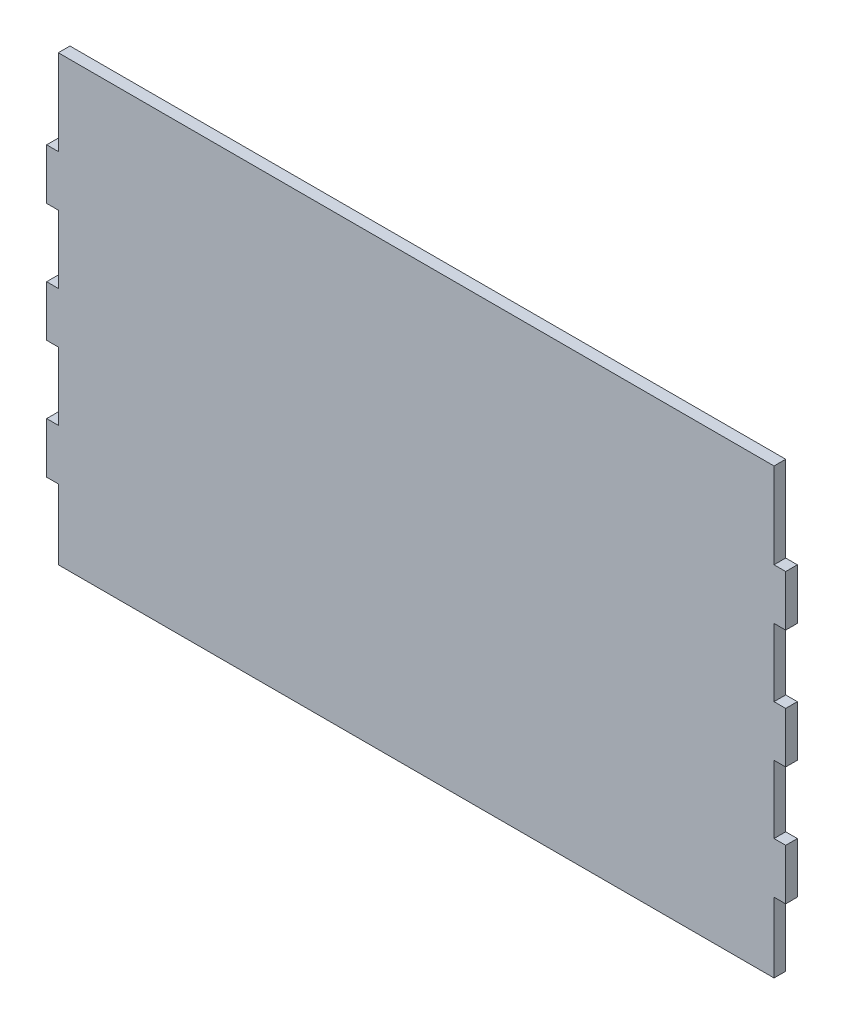
from build123d import *

# Parameters (mm, degrees)
CROQUIS1_W              = 190
CROQUIS1_H              = 110
SALIENTE_EXTRUIR1_DEPTH = 3
CROQUIS2_W              = 3
CROQUIS2_H              = 17.427708433
CORTAR_EXTRUIR1_DEPTH   = 3
CROQUIS4_W              = 184
CROQUIS4_H              = 4
SALIENTE_EXTRUIR3_DEPTH = 3
CROQUIS6_W              = 3.205128205
CROQUIS6_H              = 25
CORTAR_EXTRUIR4_DEPTH   = 1.5


with BuildPart() as part:
    # Croquis1 → Saliente-Extruir1 (new body)
    with BuildSketch(Plane.XY):
        Rectangle(CROQUIS1_W, CROQUIS1_H)
    extrude(amount=SALIENTE_EXTRUIR1_DEPTH)

    # Croquis2 → Cortar-Extruir1 (cut)
    with BuildSketch(Plane.XY.offset(3)):
        Polygon((-95, 55), (-95, 37), (-92, 37), (-92, 52), (-92, 55), align=None)
        with Locations((-93.5, 15.237951406)):
            Rectangle(CROQUIS2_W, CROQUIS2_H)
        Polygon((92, 55), (92, 52), (92, 37), (95, 37), (95, 55), align=None)
        with Locations((93.5, 15.237951406)):
            Rectangle(CROQUIS2_W, CROQUIS2_H)
        with Locations((93.5, -15.237951406)):
            Rectangle(CROQUIS2_W, CROQUIS2_H)
        Polygon((92, -37), (92, -52), (92, -55), (95, -55), (95, -37), align=None)
        with Locations((-93.5, -15.237951406)):
            Rectangle(CROQUIS2_W, CROQUIS2_H)
        Polygon((-92, -37), (-95, -37), (-95, -55), (-92, -55), (-92, -52), align=None)
    extrude(amount=-CORTAR_EXTRUIR1_DEPTH, mode=Mode.SUBTRACT)

    # Croquis4 → Saliente-Extruir3 (add)
    with BuildSketch(Plane(origin=(0, 0, 0), x_dir=(-1, 0, 0), z_dir=(0, 0, -1))):
        with Locations((0, 57)):
            Rectangle(CROQUIS4_W, CROQUIS4_H)
    extrude(amount=-SALIENTE_EXTRUIR3_DEPTH)

    # Croquis6 → Cortar-Extruir4 (cut)
    with BuildSketch(Plane(origin=(0, 0, 0), x_dir=(-1, 0, 0), z_dir=(0, 0, -1))):
        with Locations((-55.769230769, 1.792158121)):
            Rectangle(CROQUIS6_W, CROQUIS6_H)
        Polygon((-50, 11.728055557), (-50, 14.292158121), (-31.41025641, 14.292158121), (-31.41025641, 11.728055557), (-39.102564103, 11.728055557), (-39.102564103, -10.707841879), (-42.307692308, -10.707841879), (-42.307692308, 11.728055557), align=None)
        Polygon((-12.179487179, 14.292158121), (3.846153846, -10.707841879), (0.310496795, -10.707841879), (-4.827724359, -2.695021367), (-20.177283654, -2.695021367), (-25.305488782, -10.707841879), (-28.846153846, -10.707841879), (-12.820512821, 14.292158121), align=None)
        Polygon((-12.5, 9.279137287), (-18.529647436, -0.130918802), (-6.470352564, -0.130918802), align=None, mode=Mode.SUBTRACT)
        Polygon((7.692307692, -10.707841879), (12.329727564, 14.292158121), (13.090945513, 14.292158121), (26.762820513, -6.220662392), (40.389623397, 14.292158121), (41.17588141, 14.292158121), (45.833333333, -10.707841879), (42.608173077, -10.707841879), (39.262820513, 7.240876069), (27.338741987, -10.707841879), (26.231971154, -10.707841879), (14.262820513, 7.240876069), (10.932491987, -10.707841879), align=None)
    extrude(amount=-CORTAR_EXTRUIR4_DEPTH, mode=Mode.SUBTRACT)


solid = part.part
